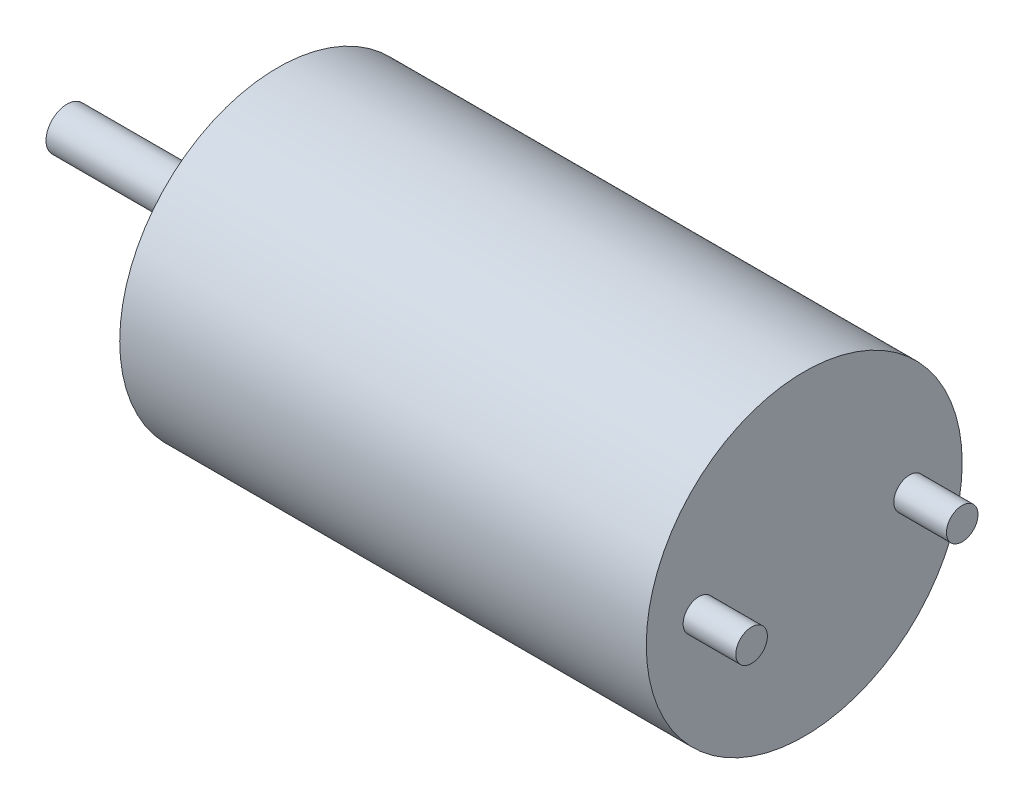
from build123d import *

# Parameters (mm, degrees)
SKETCH1_R           = 3
BOSS_EXTRUDE1_DEPTH = 10
SKETCH2_R           = 1.2
BOSS_EXTRUDE2_DEPTH = 0.8
SKETCH3_R           = 0.4
BOSS_EXTRUDE3_DEPTH = 3.2
SKETCH4_R           = 0.3
BOSS_EXTRUDE4_DEPTH = 1


with BuildPart() as part:
    # Sketch1 → Boss-Extrude1 (new body)
    with BuildSketch(Plane(origin=(0, 0, 0), x_dir=(0, 0, -1), z_dir=(1, 0, 0))):
        Circle(SKETCH1_R)
    extrude(amount=BOSS_EXTRUDE1_DEPTH)

    # Sketch2 → Boss-Extrude2 (add)
    with BuildSketch(Plane.ZY):
        Circle(SKETCH2_R)
    extrude(amount=BOSS_EXTRUDE2_DEPTH)

    # Sketch3 → Boss-Extrude3 (add)
    with BuildSketch(Plane.ZY.offset(0.8)):
        Circle(SKETCH3_R)
    extrude(amount=BOSS_EXTRUDE3_DEPTH)

    # Sketch4 → Boss-Extrude4 (add)
    with BuildSketch(Plane(origin=(10, 0, 0), x_dir=(0, 0, -1), z_dir=(1, 0, 0))):
        with Locations((-2, 0)):
            Circle(SKETCH4_R)
        with Locations((2, 0)):
            Circle(SKETCH4_R)
    extrude(amount=BOSS_EXTRUDE4_DEPTH)


solid = part.part
